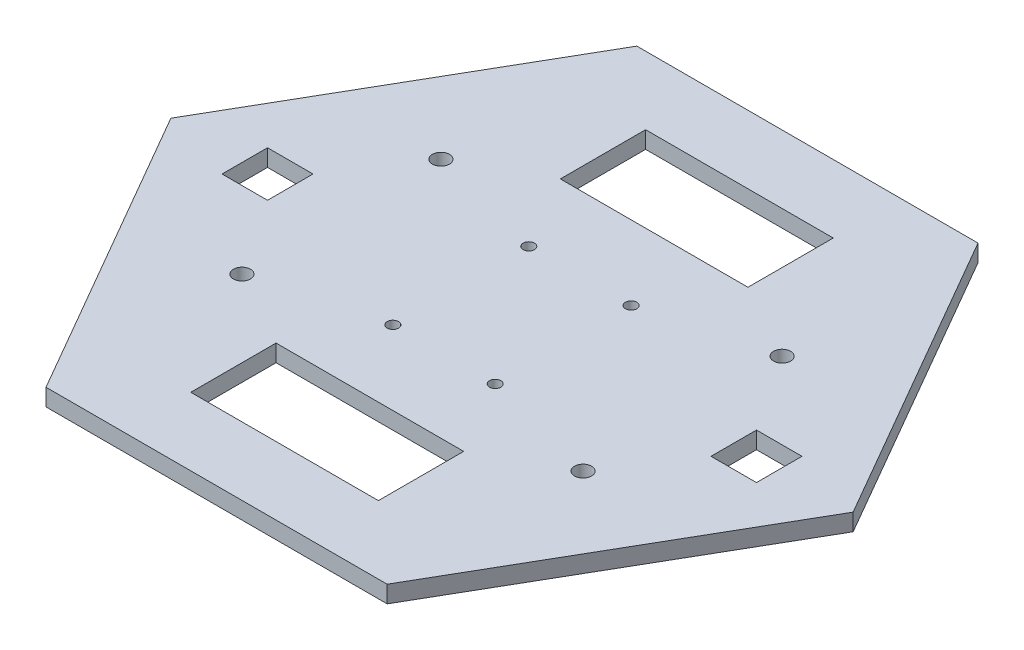
from build123d import *

# Parameters (mm, degrees)
SALIENTE_EXTRUIR1_DEPTH = 3
CROQUIS3_W              = 33
CROQUIS3_H              = 15
CORTAR_EXTRUIR1_DEPTH   = 4
CROQUIS4_R              = 1
CORTAR_EXTRUIR2_DEPTH   = 4
CROQUIS5_W              = 8
CROQUIS5_H              = 8
CORTAR_EXTRUIR3_DEPTH   = 4
CROQUIS6_R              = 1.5
CORTAR_EXTRUIR4_DEPTH   = 4


with BuildPart() as part:
    # Croquis1 → Saliente-Extruir1 (new body)
    with BuildSketch(Plane(origin=(0, 0, 0), x_dir=(1, 0, 0), z_dir=(0, 1, 0))):
        Polygon((-60, 0), (-30, -51.961524227), (30, -51.961524227), (60, 0), (30, 51.961524227), (-30, 51.961524227), align=None)
    extrude(amount=SALIENTE_EXTRUIR1_DEPTH)

    # Croquis3 → Cortar-Extruir1 (cut, through all)
    with BuildSketch(Plane(origin=(0, 3, 0), x_dir=(1, 0, 0), z_dir=(0, 1, 0))):
        with Locations((0, -32.5)):
            Rectangle(CROQUIS3_W, CROQUIS3_H)
        with Locations((0, 32.5)):
            Rectangle(CROQUIS3_W, CROQUIS3_H)
    extrude(amount=-CORTAR_EXTRUIR1_DEPTH, mode=Mode.SUBTRACT)

    # Croquis4 → Cortar-Extruir2 (cut, through all)
    with BuildSketch(Plane(origin=(0, 3, 0), x_dir=(1, 0, 0), z_dir=(0, 1, 0))):
        with Locations((-9, -11.95)):
            Circle(CROQUIS4_R)
        with Locations((9, -11.95)):
            Circle(CROQUIS4_R)
        with Locations((9, 11.95)):
            Circle(CROQUIS4_R)
        with Locations((-9, 11.95)):
            Circle(CROQUIS4_R)
    extrude(amount=-CORTAR_EXTRUIR2_DEPTH, mode=Mode.SUBTRACT)

    # Croquis5 → Cortar-Extruir3 (cut, through all)
    with BuildSketch(Plane(origin=(0, 3, 0), x_dir=(1, 0, 0), z_dir=(0, 1, 0))):
        with Locations((-43, 0)):
            Rectangle(CROQUIS5_W, CROQUIS5_H)
        with Locations((43, 0)):
            Rectangle(CROQUIS5_W, CROQUIS5_H)
    extrude(amount=-CORTAR_EXTRUIR3_DEPTH, mode=Mode.SUBTRACT)

    # Croquis6 → Cortar-Extruir4 (cut, through all)
    with BuildSketch(Plane(origin=(0, 3, 0), x_dir=(1, 0, 0), z_dir=(0, 1, 0))):
        with Locations((-30, -17.5)):
            Circle(CROQUIS6_R)
        with Locations((-30, 17.5)):
            Circle(CROQUIS6_R)
        with Locations((30, 17.5)):
            Circle(CROQUIS6_R)
        with Locations((30, -17.5)):
            Circle(CROQUIS6_R)
    extrude(amount=-CORTAR_EXTRUIR4_DEPTH, mode=Mode.SUBTRACT)


solid = part.part
